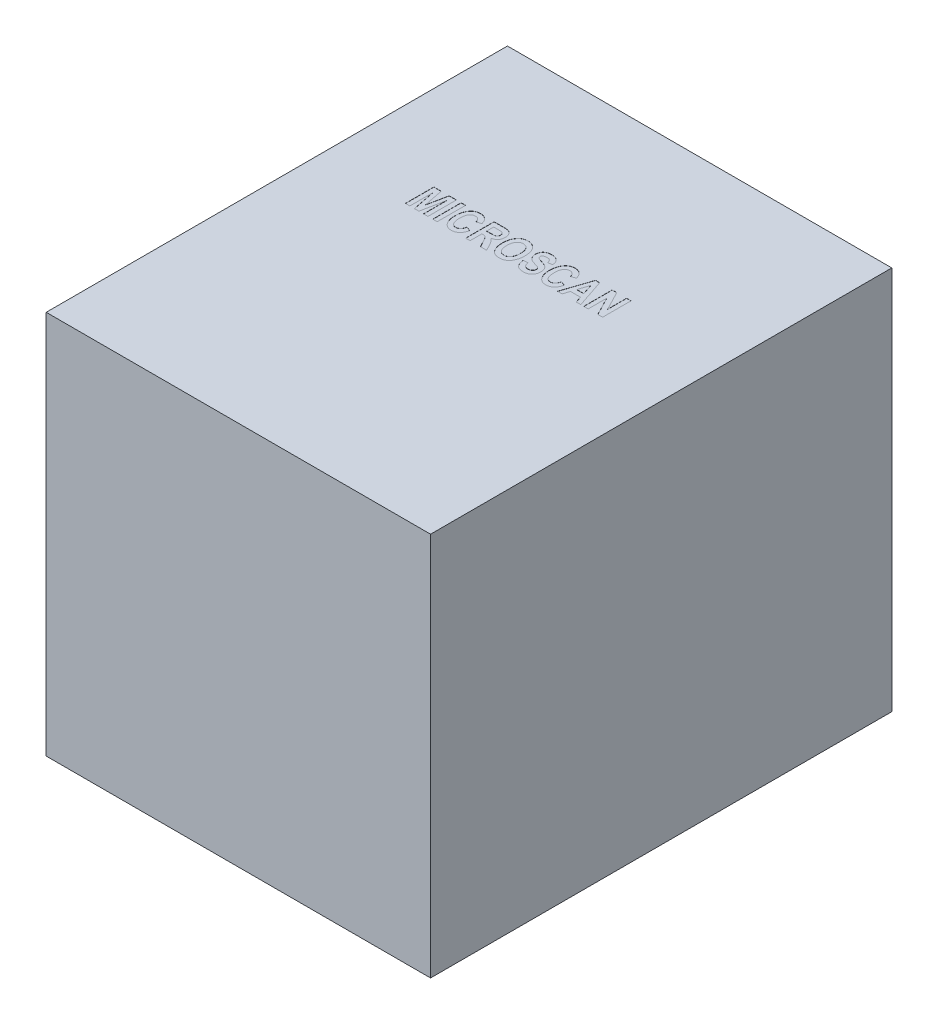
from build123d import *

# Parameters (mm, degrees)
SKETCH1_W           = 250
SKETCH1_H           = 250
BOSS_EXTRUDE1_DEPTH = 300
SKETCH2_W           = 2.881853693
SKETCH2_H           = 18.491894532
CUT_EXTRUDE1_DEPTH  = 0.1


with BuildPart() as part:
    # Sketch1 → Boss-Extrude1 (new body)
    with BuildSketch(Plane.XY):
        Rectangle(SKETCH1_W, SKETCH1_H)
    extrude(amount=BOSS_EXTRUDE1_DEPTH)

    # Sketch2 → Cut-Extrude1 (cut)
    with BuildSketch(Plane(origin=(0, 125, 0), x_dir=(1, 0, 0), z_dir=(0, 1, 0))):
        Polygon((-69.512052885, -121.832281684), (-69.512052885, -103.340387152), (-64.74273512, -103.340387152), (-62.187341415, -116.196156362), (-59.583166333, -103.340387152), (-54.862629945, -103.340387152), (-54.862629945, -121.832281684), (-57.744483638, -121.832281684), (-57.744483638, -107.03651461), (-60.750166982, -121.832281684), (-63.680802053, -121.832281684), (-66.630199192, -107.03651461), (-66.630199192, -121.832281684), align=None)
        with Locations((-50.299694931, -112.586334418)):
            Rectangle(SKETCH2_W, SKETCH2_H)
        with BuildLine():
            Line((-36.130580939, -115.107956399), (-33.248727246, -116.308728772))
            add(Edge.make_bspline(
                [(-33.248727246, -116.308728772), (-33.308245743, -116.550975126), (-33.424220471, -117.023004107), (-33.643628678, -117.697666192), (-33.885062341, -118.323649851), (-34.161276007, -118.897451219), (-34.462799732, -119.424104457), (-34.797731244, -119.898427101), (-35.159769117, -120.32284771), (-35.55097253, -120.696374595), (-35.970707039, -121.017764628), (-36.407187584, -121.304155773), (-36.87168537, -121.538935512), (-37.357696184, -121.737170875), (-37.869040952, -121.884525922), (-38.401834597, -121.995416695), (-38.958363997, -122.058873566), (-39.33748846, -122.067864433), (-39.530267718, -122.072436158)],
                knots=[0, 0, 0, 0, 0.000748124, 0.001457757, 0.002126709, 0.002759444, 0.003366373, 0.003945231, 0.004498759, 0.005037554, 0.005564458, 0.006082794, 0.00660136, 0.00712327, 0.007655213, 0.008195378, 0.008754387, 0.009332697, 0.009332697, 0.009332697, 0.009332697], degree=3))
            add(Edge.make_bspline(
                [(-39.530267718, -122.072436158), (-39.772147001, -122.066998117), (-40.245982801, -122.056345123), (-40.937400287, -121.941721554), (-41.595343591, -121.767571007), (-42.218626723, -121.517489733), (-42.807988765, -121.197832615), (-43.357203628, -120.801890323), (-43.879086754, -120.344403118), (-44.182525847, -119.987697921), (-44.33710962, -119.805978306)],
                knots=[0, 0, 0, 0, 0.000725003, 0.001420263, 0.002096583, 0.002763426, 0.003430058, 0.004102693, 0.004791065, 0.005505926, 0.005505926, 0.005505926, 0.005505926], degree=3))
            add(Edge.make_bspline(
                [(-44.33710962, -119.805978306), (-44.507028249, -119.581622631), (-44.849345032, -119.129637387), (-45.27910475, -118.384314521), (-45.644623638, -117.583590363), (-45.94378282, -116.726739165), (-46.176961635, -115.812811637), (-46.339983902, -114.841372068), (-46.437883745, -113.812890342), (-46.450679072, -113.108138763), (-46.45722334, -112.747688205)],
                knots=[0, 0, 0, 0, 0.000843651, 0.001699612, 0.00257444, 0.003481128, 0.00441854, 0.005400641, 0.006433421, 0.007514643, 0.007514643, 0.007514643, 0.007514643], degree=3))
            add(Edge.make_bspline(
                [(-46.45722334, -112.747688205), (-46.451244677, -112.367181685), (-46.439599246, -111.626018829), (-46.334749776, -110.546956168), (-46.174911255, -109.529656896), (-45.936598651, -108.57790215), (-45.638059623, -107.68622688), (-45.269215514, -106.860191453), (-44.840950487, -106.091156805), (-44.491535179, -105.631863367), (-44.318347552, -105.404214667)],
                knots=[0, 0, 0, 0, 0.001141234, 0.002222931, 0.003249448, 0.0042278, 0.005162866, 0.006066598, 0.006938814, 0.007795984, 0.007795984, 0.007795984, 0.007795984], degree=3))
            add(Edge.make_bspline(
                [(-44.318347552, -105.404214667), (-44.161101744, -105.220196591), (-43.851203985, -104.857536436), (-43.321514999, -104.387917013), (-42.75246272, -103.988723778), (-42.144253064, -103.661885925), (-41.494164515, -103.407682111), (-40.805378766, -103.228311936), (-40.075138045, -103.122476347), (-39.575647713, -103.107760563), (-39.320132553, -103.100232678)],
                knots=[0, 0, 0, 0, 0.000725459, 0.001429724, 0.002116785, 0.00280679, 0.003495949, 0.004205869, 0.004937667, 0.005704078, 0.005704078, 0.005704078, 0.005704078], degree=3))
            add(Edge.make_bspline(
                [(-39.320132553, -103.100232678), (-39.111027938, -103.105237872), (-38.700042629, -103.115075347), (-38.097407195, -103.193720573), (-37.523248784, -103.332007207), (-36.97196277, -103.513396119), (-36.44838585, -103.756092612), (-35.951004084, -104.050590643), (-35.477861501, -104.395921998), (-35.191082298, -104.664384902), (-35.046133391, -104.800076067)],
                knots=[0, 0, 0, 0, 0.000627203, 0.001232739, 0.001818884, 0.002396768, 0.002970986, 0.003546318, 0.004128716, 0.00472392, 0.00472392, 0.00472392, 0.00472392], degree=3))
            add(Edge.make_bspline(
                [(-35.046133391, -104.800076067), (-34.945351822, -104.904655694), (-34.739987328, -105.117759562), (-34.463463574, -105.476719718), (-34.207450557, -105.872044764), (-33.976538318, -106.305421764), (-33.761866544, -106.772614942), (-33.566661836, -107.276019097), (-33.394936079, -107.816779469), (-33.298216436, -108.191761527), (-33.248727246, -108.383631115)],
                knots=[0, 0, 0, 0, 0.000435442, 0.000887308, 0.00135672, 0.001846966, 0.002359071, 0.002898428, 0.003465675, 0.004060051, 0.004060051, 0.004060051, 0.004060051], degree=3))
            Line((-33.248727246, -108.383631115), (-36.130580939, -109.344249013))
            add(Edge.make_bspline(
                [(-36.130580939, -109.344249013), (-36.157661563, -109.221255235), (-36.210355959, -108.981929771), (-36.316152908, -108.63655056), (-36.444956461, -108.315761909), (-36.585096417, -108.011862834), (-36.753848249, -107.73536473), (-36.93036798, -107.47305635), (-37.137353894, -107.240661297), (-37.356028781, -107.025968121), (-37.594105924, -106.840437629), (-37.837799279, -106.672654244), (-38.094374282, -106.533154659), (-38.362760688, -106.420961924), (-38.639779692, -106.330164088), (-38.927495512, -106.26631282), (-39.225249698, -106.227646659), (-39.427583715, -106.224060707), (-39.530267718, -106.222240845)],
                knots=[0, 0, 0, 0, 0.000377728, 0.000734997, 0.001082009, 0.001414347, 0.001737403, 0.002052807, 0.002361327, 0.002669162, 0.002970969, 0.003265504, 0.003555995, 0.003845223, 0.004137141, 0.004429372, 0.004728178, 0.005036082, 0.005036082, 0.005036082, 0.005036082], degree=3))
            add(Edge.make_bspline(
                [(-39.530267718, -106.222240845), (-39.675591067, -106.226549519), (-39.961602282, -106.23502943), (-40.38063334, -106.302497335), (-40.777093646, -106.421829236), (-41.156952055, -106.578488507), (-41.513825515, -106.787205322), (-41.851686875, -107.039964321), (-42.161451398, -107.34440406), (-42.458328016, -107.686846522), (-42.727348467, -108.083609145), (-42.955765195, -108.542161233), (-43.144167535, -109.060865755), (-43.306453933, -109.636002594), (-43.427874002, -110.271350471), (-43.512135797, -110.965925492), (-43.564724652, -111.718720414), (-43.571739715, -112.241022053), (-43.575369647, -112.511286145)],
                knots=[0, 0, 0, 0, 0.000435862, 0.000857821, 0.001268637, 0.001675631, 0.002087543, 0.002505563, 0.002938133, 0.003387875, 0.0038635, 0.004371976, 0.004920522, 0.005516885, 0.006163019, 0.006858837, 0.007614899, 0.008425638, 0.008425638, 0.008425638, 0.008425638], degree=3))
            add(Edge.make_bspline(
                [(-43.575369647, -112.511286145), (-43.571268008, -112.791518101), (-43.563369493, -113.331159978), (-43.517327512, -114.110583737), (-43.429812626, -114.82669565), (-43.317786926, -115.482311511), (-43.16449025, -116.073599201), (-42.977208758, -116.600920856), (-42.761490268, -117.069424538), (-42.504161246, -117.472963397), (-42.219035589, -117.821337574), (-41.915894882, -118.123802259), (-41.58888664, -118.376469421), (-41.246759196, -118.59060339), (-40.88011977, -118.752868428), (-40.493305862, -118.863269922), (-40.088611525, -118.939629283), (-39.810814167, -118.946780225), (-39.669107024, -118.95042799)],
                knots=[0, 0, 0, 0, 0.00084075, 0.00161903, 0.002340919, 0.00300412, 0.003613006, 0.004170843, 0.004681129, 0.005156858, 0.005602259, 0.006029457, 0.006438539, 0.006839486, 0.007237631, 0.007636589, 0.008044378, 0.008468998, 0.008468998, 0.008468998, 0.008468998], degree=3))
            add(Edge.make_bspline(
                [(-39.669107024, -118.95042799), (-39.565176792, -118.94720921), (-39.359008339, -118.940824051), (-39.055629668, -118.900165212), (-38.76287434, -118.827467968), (-38.480702869, -118.726608782), (-38.210317863, -118.593537978), (-37.948945173, -118.435887714), (-37.701864847, -118.246390382), (-37.462665743, -118.031225479), (-37.237057828, -117.78374781), (-37.030869437, -117.499218197), (-36.83929712, -117.182721914), (-36.663499019, -116.832296092), (-36.50235394, -116.450192983), (-36.360271354, -116.033480409), (-36.231699808, -115.584238807), (-36.164936459, -115.269775158), (-36.130580939, -115.107956399)],
                knots=[0, 0, 0, 0, 0.000311812, 0.000618547, 0.000916149, 0.001215262, 0.001515666, 0.001818776, 0.00212948, 0.00244828, 0.002782982, 0.003131977, 0.003500727, 0.003891735, 0.004307102, 0.004743803, 0.005211817, 0.00570796, 0.00570796, 0.00570796, 0.00570796], degree=3))
        make_face()
        with BuildLine():
            Line((-30.366873553, -121.832281684), (-30.366873553, -103.340387152))
            Line((-30.366873553, -103.340387152), (-23.875197916, -103.340387152))
            add(Edge.make_bspline(
                [(-23.875197916, -103.340387152), (-23.675057607, -103.341851226), (-23.289649913, -103.344670576), (-22.732520302, -103.365438256), (-22.220977299, -103.408440344), (-21.752128088, -103.457954239), (-21.329978896, -103.528766813), (-20.951451163, -103.614889943), (-20.617052779, -103.714304306), (-20.229207416, -103.86890571), (-19.794637529, -104.124732531), (-19.327311543, -104.517039685), (-18.911566219, -105.003019248), (-18.546628352, -105.571404362), (-18.245371653, -106.216351583), (-18.034126145, -106.930836609), (-17.89840513, -107.704290931), (-17.885495704, -108.241688867), (-17.878840883, -108.518718007)],
                knots=[0, 0, 0, 0, 0.000600433, 0.001156246, 0.001671982, 0.002140237, 0.002570212, 0.002955251, 0.003304245, 0.003615718, 0.004205898, 0.0048079, 0.005438361, 0.006116999, 0.006828811, 0.007565976, 0.008346352, 0.009176662, 0.009176662, 0.009176662, 0.009176662], degree=3))
            add(Edge.make_bspline(
                [(-17.878840883, -108.518718007), (-17.882959025, -108.695182705), (-17.891006767, -109.040032963), (-17.938747147, -109.544607506), (-18.023948209, -110.023305924), (-18.149947807, -110.473956259), (-18.301506928, -110.901667028), (-18.494729482, -111.300438966), (-18.720313605, -111.674008778), (-18.979599565, -112.019408637), (-19.269727389, -112.336396038), (-19.590583568, -112.622481079), (-19.940019556, -112.879718136), (-20.322616294, -113.098859691), (-20.728147591, -113.297417019), (-21.166619996, -113.456658766), (-21.632976673, -113.589822519), (-21.957125605, -113.6508459), (-22.122820735, -113.682039207)],
                knots=[0, 0, 0, 0, 0.000529423, 0.001034607, 0.001518916, 0.001985922, 0.002436992, 0.002878392, 0.003312781, 0.003744309, 0.004171903, 0.00459976, 0.00503207, 0.00547099, 0.005920779, 0.006385003, 0.006868482, 0.007374057, 0.007374057, 0.007374057, 0.007374057], degree=3))
            add(Edge.make_bspline(
                [(-22.122820735, -113.682039207), (-21.958557305, -113.798658374), (-21.637154645, -114.026838865), (-21.192287022, -114.399875697), (-20.794329961, -114.790850175), (-20.489478771, -115.136808758), (-20.259493026, -115.445724373), (-20.068011841, -115.715098496), (-19.862476092, -116.027299628), (-19.64022376, -116.380876203), (-19.405387195, -116.778431968), (-19.153964082, -117.217510831), (-18.887157059, -117.69959873), (-18.705323069, -118.035927234), (-18.610561547, -118.211202499)],
                knots=[0, 0, 0, 0, 0.000604185, 0.001182167, 0.001739397, 0.002276661, 0.002563346, 0.002894431, 0.003268056, 0.003684506, 0.004147211, 0.004653133, 0.005202384, 0.005800138, 0.005800138, 0.005800138, 0.005800138], degree=3))
            Line((-18.610561547, -118.211202499), (-16.67806851, -121.832281684))
            Line((-16.67806851, -121.832281684), (-20.726922853, -121.832281684))
            Line((-20.726922853, -121.832281684), (-22.869551054, -117.832208719))
            add(Edge.make_bspline(
                [(-22.869551054, -117.832208719), (-22.961757882, -117.659407949), (-23.137240325, -117.330544003), (-23.393057355, -116.864316303), (-23.625547224, -116.449665206), (-23.830993428, -116.082402527), (-24.01893787, -115.770074703), (-24.179365324, -115.503924241), (-24.320998334, -115.292077528), (-24.47383548, -115.078048208), (-24.652307712, -114.862758389), (-24.875513545, -114.650253733), (-25.103812096, -114.479105798), (-25.35008119, -114.347900463), (-25.635196001, -114.249266443), (-25.982303031, -114.193631292), (-26.398200074, -114.149667633), (-26.699348992, -114.148155698), (-26.862119192, -114.147338502)],
                knots=[0, 0, 0, 0, 0.000587585, 0.001118257, 0.001595345, 0.002013768, 0.002380585, 0.002688854, 0.002945915, 0.003144828, 0.00347778, 0.00378302, 0.004067462, 0.004331014, 0.00461701, 0.004968077, 0.005382901, 0.005870845, 0.005870845, 0.005870845, 0.005870845], degree=3))
            Line((-26.862119192, -114.147338502), (-27.48501986, -114.147338502))
            Line((-27.48501986, -114.147338502), (-27.48501986, -121.832281684))
            Line((-27.48501986, -121.832281684), (-30.366873553, -121.832281684))
        make_face()
        with BuildLine():
            Line((-27.48501986, -111.025330334), (-25.019684083, -111.025330334))
            add(Edge.make_bspline(
                [(-25.019684083, -111.025330334), (-24.839568727, -111.024275742), (-24.496833907, -111.022268997), (-24.008915709, -111.016378036), (-23.572392377, -111.000457627), (-23.188312661, -110.982422833), (-22.854109318, -110.960710581), (-22.572097882, -110.93291823), (-22.34056348, -110.895006065), (-22.101383067, -110.842836305), (-21.847796136, -110.746467225), (-21.581146695, -110.584494087), (-21.339623238, -110.383766999), (-21.133150012, -110.133124813), (-20.961330408, -109.838074651), (-20.843440677, -109.495328753), (-20.770691689, -109.1096757), (-20.764141548, -108.83803221), (-20.760694576, -108.695081449)],
                knots=[0, 0, 0, 0, 0.000540361, 0.001028232, 0.001463771, 0.001850725, 0.002181704, 0.002468463, 0.002700415, 0.0028852, 0.003202296, 0.003508618, 0.003817549, 0.004139929, 0.004477834, 0.004836263, 0.005221904, 0.005650272, 0.005650272, 0.005650272, 0.005650272], degree=3))
            add(Edge.make_bspline(
                [(-20.760694576, -108.695081449), (-20.764325534, -108.558408702), (-20.771276786, -108.296756938), (-20.842575898, -107.925523978), (-20.962472367, -107.595895696), (-21.133751675, -107.310750913), (-21.346208995, -107.069865137), (-21.591861576, -106.865485305), (-21.87332002, -106.70250145), (-22.08133041, -106.632773815), (-22.186611768, -106.597482212)],
                knots=[0, 0, 0, 0, 0.000409632, 0.000784216, 0.00112854, 0.001456742, 0.001775852, 0.002087664, 0.002412068, 0.002744533, 0.002744533, 0.002744533, 0.002744533], degree=3))
            add(Edge.make_bspline(
                [(-22.186611768, -106.597482212), (-22.234047873, -106.586997883), (-22.346959079, -106.562042246), (-22.546049369, -106.53277802), (-22.801777801, -106.512793667), (-23.112037668, -106.494096558), (-23.477356902, -106.479894022), (-23.897632335, -106.467561861), (-24.373026544, -106.466567594), (-24.708236971, -106.463833681), (-24.884597191, -106.46239532)],
                knots=[0, 0, 0, 0, 0.000145717, 0.000346848, 0.000603004, 0.000915019, 0.001279312, 0.001699733, 0.002176304, 0.002705408, 0.002705408, 0.002705408, 0.002705408], degree=3))
            Line((-24.884597191, -106.46239532), (-27.48501986, -106.46239532))
            Line((-27.48501986, -106.46239532), (-27.48501986, -111.025330334))
        make_face(mode=Mode.SUBTRACT)
        with BuildLine():
            add(Edge.make_bspline(
                [(-15.717450613, -112.698906828), (-15.714742498, -112.431162632), (-15.709448806, -111.907789105), (-15.663114611, -111.141660822), (-15.590760326, -110.411125062), (-15.479637061, -109.71809955), (-15.348666162, -109.058939898), (-15.176253638, -108.439045196), (-14.985518604, -107.851207447), (-14.752904257, -107.303679258), (-14.502920708, -106.787783586), (-14.228610049, -106.309145489), (-13.938809536, -105.861496941), (-13.627337384, -105.450411245), (-13.30061535, -105.069104649), (-12.95593238, -104.722257492), (-12.588391349, -104.413992236), (-12.205436104, -104.133617676), (-11.79917974, -103.88997034), (-11.372957855, -103.679973321), (-10.928665797, -103.497937817), (-10.461619327, -103.351618568), (-9.973086841, -103.240755069), (-9.464530766, -103.157240773), (-8.935327422, -103.107830083), (-8.575460441, -103.10279117), (-8.392739143, -103.100232678)],
                knots=[0, 0, 0, 0, 0.000803157, 0.001569972, 0.002301799, 0.003004473, 0.003674896, 0.004316657, 0.004933698, 0.005527446, 0.006099711, 0.006652641, 0.007181359, 0.007698444, 0.008198656, 0.008686874, 0.009163489, 0.009636353, 0.010109351, 0.010582586, 0.011060603, 0.011548374, 0.012049008, 0.012562266, 0.013093601, 0.013641659, 0.013641659, 0.013641659, 0.013641659], degree=3))
            add(Edge.make_bspline(
                [(-8.392739143, -103.100232678), (-8.128350767, -103.106763931), (-7.609412175, -103.119583402), (-6.851037102, -103.240529661), (-6.12890729, -103.430040989), (-5.444691849, -103.702231494), (-4.799652549, -104.054162606), (-4.192109905, -104.481364238), (-3.621842424, -104.984424641), (-3.094113344, -105.563326551), (-2.612383652, -106.210347599), (-2.1994831, -106.931400876), (-1.845024666, -107.713396717), (-1.562597273, -108.564652656), (-1.33587271, -109.477565867), (-1.183810433, -110.457171914), (-1.0816012, -111.499714387), (-1.072640183, -112.217082878), (-1.068027672, -112.586334418)],
                knots=[0, 0, 0, 0, 0.000792648, 0.001555801, 0.002297622, 0.003028572, 0.003758993, 0.004497084, 0.00525215, 0.00603565, 0.006843186, 0.00766701, 0.008523514, 0.009414671, 0.010353892, 0.011342167, 0.012386154, 0.013493523, 0.013493523, 0.013493523, 0.013493523], degree=3))
            add(Edge.make_bspline(
                [(-1.068027672, -112.586334418), (-1.074173471, -112.959314722), (-1.086159026, -113.686702032), (-1.188968258, -114.746347802), (-1.355552548, -115.743986878), (-1.591072012, -116.678375325), (-1.895197823, -117.550577942), (-2.267454436, -118.360030173), (-2.70385526, -119.111140753), (-3.055305788, -119.560731841), (-3.229417942, -119.783463824)],
                knots=[0, 0, 0, 0, 0.001118729, 0.002181749, 0.003190374, 0.00415053, 0.005069082, 0.005957271, 0.006820269, 0.007667567, 0.007667567, 0.007667567, 0.007667567], degree=3))
            add(Edge.make_bspline(
                [(-3.229417942, -119.783463824), (-3.390459268, -119.966317288), (-3.708127215, -120.327011566), (-4.251309948, -120.794348831), (-4.834486499, -121.191887695), (-5.464005744, -121.511174817), (-6.132669153, -121.765244491), (-6.845180163, -121.944695204), (-7.60032922, -122.050095984), (-8.117225278, -122.064878687), (-8.381481902, -122.072436158)],
                knots=[0, 0, 0, 0, 0.000730257, 0.001440495, 0.002143008, 0.002842821, 0.003552989, 0.00428471, 0.005042512, 0.00583516, 0.00583516, 0.00583516, 0.00583516], degree=3))
            add(Edge.make_bspline(
                [(-8.381481902, -122.072436158), (-8.648336915, -122.067052107), (-9.16939353, -122.056539301), (-9.928154051, -121.942321884), (-10.644926872, -121.769250469), (-11.317594962, -121.52022173), (-11.946328095, -121.199045514), (-12.529342601, -120.804530684), (-13.078335754, -120.347350137), (-13.395397996, -119.988045696), (-13.556060343, -119.805978306)],
                knots=[0, 0, 0, 0, 0.000799977, 0.001562022, 0.00229647, 0.003008836, 0.003708649, 0.004409065, 0.005117268, 0.005844771, 0.005844771, 0.005844771, 0.005844771], degree=3))
            add(Edge.make_bspline(
                [(-13.556060343, -119.805978306), (-13.729896006, -119.583075734), (-14.079464582, -119.134837823), (-14.518249717, -118.390436125), (-14.890317155, -117.58821685), (-15.193153674, -116.725686777), (-15.430199964, -115.804228977), (-15.596194758, -114.822675445), (-15.699408836, -113.780563742), (-15.711333564, -113.065641651), (-15.717450613, -112.698906828)],
                knots=[0, 0, 0, 0, 0.000847298, 0.001703843, 0.002585221, 0.003496695, 0.004442311, 0.005436141, 0.006480485, 0.007580461, 0.007580461, 0.007580461, 0.007580461], degree=3))
        make_face()
        with BuildLine():
            add(Edge.make_bspline(
                [(-12.83559692, -112.575077177), (-12.832549165, -112.832870155), (-12.826651779, -113.331698049), (-12.765711193, -114.054919657), (-12.666409792, -114.728577048), (-12.523802862, -115.353188805), (-12.34499019, -115.928586879), (-12.12856781, -116.456262319), (-11.864277025, -116.930703314), (-11.563421462, -117.356093503), (-11.233690113, -117.73082511), (-10.882610113, -118.056234001), (-10.512589351, -118.33360834), (-10.122112377, -118.559161591), (-9.711362823, -118.73458568), (-9.282671204, -118.857005524), (-8.834617958, -118.935458429), (-8.529407304, -118.945376936), (-8.373977074, -118.95042799)],
                knots=[0, 0, 0, 0, 0.000773225, 0.001496186, 0.002175466, 0.002814479, 0.003416189, 0.00398136, 0.004522228, 0.005041758, 0.005541604, 0.006016918, 0.006475466, 0.006926005, 0.007366495, 0.007811832, 0.008260932, 0.008726972, 0.008726972, 0.008726972, 0.008726972], degree=3))
            add(Edge.make_bspline(
                [(-8.373977074, -118.95042799), (-8.217374639, -118.944916937), (-7.91003453, -118.93410122), (-7.458558083, -118.862462015), (-7.029052138, -118.738105021), (-6.620255884, -118.563129848), (-6.230273079, -118.341778205), (-5.866799647, -118.063150922), (-5.517726375, -117.743518886), (-5.195224259, -117.369069475), (-4.898058831, -116.946595104), (-4.640981635, -116.468135394), (-4.429315563, -115.935800382), (-4.253815758, -115.351793715), (-4.11491727, -114.715883259), (-4.020712669, -114.02703377), (-3.958573337, -113.286676513), (-3.952841382, -112.775342247), (-3.949881366, -112.511286145)],
                knots=[0, 0, 0, 0, 0.000469787, 0.00092198, 0.001367317, 0.001807806, 0.002253223, 0.002708766, 0.003178778, 0.003670859, 0.00418823, 0.004725494, 0.005296181, 0.005903957, 0.006553135, 0.007246723, 0.007988382, 0.008780364, 0.008780364, 0.008780364, 0.008780364], degree=3))
            add(Edge.make_bspline(
                [(-3.949881366, -112.511286145), (-3.953421357, -112.252286666), (-3.960287953, -111.74989988), (-4.014678084, -111.022620803), (-4.113898236, -110.348951873), (-4.240943911, -109.726433796), (-4.415506224, -109.15718652), (-4.621686167, -108.636596768), (-4.875689261, -108.172704395), (-5.161707486, -107.759150075), (-5.481934392, -107.39927647), (-5.82555466, -107.085117908), (-6.190674438, -106.816735563), (-6.579805266, -106.595272496), (-6.996651957, -106.431479598), (-7.43438183, -106.311745228), (-7.895803297, -106.232298833), (-8.212285774, -106.225641887), (-8.373977074, -106.222240845)],
                knots=[0, 0, 0, 0, 0.000776976, 0.001507117, 0.002185848, 0.002818772, 0.003411095, 0.00396994, 0.004495519, 0.004994139, 0.005475283, 0.005937454, 0.006388525, 0.006832088, 0.00727665, 0.007728189, 0.008192094, 0.008676679, 0.008676679, 0.008676679, 0.008676679], degree=3))
            add(Edge.make_bspline(
                [(-8.373977074, -106.222240845), (-8.535691421, -106.225574173), (-8.852219008, -106.232098579), (-9.314507787, -106.312705904), (-9.755007713, -106.429542894), (-10.171780288, -106.600922297), (-10.564760051, -106.82009906), (-10.934635443, -107.088856686), (-11.281213556, -107.406733642), (-11.604215139, -107.771710094), (-11.901001474, -108.185915691), (-12.150025307, -108.6597614), (-12.364109555, -109.182312584), (-12.536453142, -109.759480569), (-12.669026736, -110.38851346), (-12.765214527, -111.070478966), (-12.826901063, -111.804697475), (-12.832630496, -112.31227703), (-12.83559692, -112.575077177)],
                knots=[0, 0, 0, 0, 0.000484585, 0.00094849, 0.001403647, 0.001849616, 0.002296453, 0.002750557, 0.00321803, 0.003704471, 0.004210477, 0.004742658, 0.005306395, 0.005902309, 0.006547025, 0.007233184, 0.007967363, 0.008755594, 0.008755594, 0.008755594, 0.008755594], degree=3))
        make_face(mode=Mode.SUBTRACT)
        with BuildLine():
            Line((0.853208123, -115.588265348), (3.735061816, -115.348110874))
            add(Edge.make_bspline(
                [(3.735061816, -115.348110874), (3.758307582, -115.493547749), (3.803637674, -115.777154959), (3.89916029, -116.184880197), (4.005303451, -116.567544149), (4.138185175, -116.918575841), (4.282957528, -117.245674311), (4.452691258, -117.540528748), (4.636783175, -117.811560032), (4.843255681, -118.050628122), (5.066766819, -118.26331512), (5.307177172, -118.448901223), (5.569031135, -118.60269464), (5.847367832, -118.732007695), (6.146497556, -118.828258412), (6.462667713, -118.900553606), (6.798478864, -118.941229706), (7.028325748, -118.947313254), (7.146005836, -118.95042799)],
                knots=[0, 0, 0, 0, 0.000441702, 0.000861336, 0.001255643, 0.001632027, 0.001986367, 0.002327527, 0.002651236, 0.002967888, 0.003273128, 0.003575587, 0.003876764, 0.004182349, 0.004494432, 0.004817597, 0.005154103, 0.005507149, 0.005507149, 0.005507149, 0.005507149], degree=3))
            add(Edge.make_bspline(
                [(7.146005836, -118.95042799), (7.262419718, -118.948386773), (7.489505702, -118.944405016), (7.819401603, -118.91008914), (8.131241394, -118.854955172), (8.421920754, -118.771874077), (8.695720687, -118.669646017), (8.952222406, -118.548264843), (9.184452172, -118.395026701), (9.400022394, -118.227634131), (9.589465815, -118.038713664), (9.760695491, -117.842018904), (9.899314722, -117.628104014), (10.017361352, -117.406793292), (10.107340476, -117.17346954), (10.17078048, -116.929195621), (10.214847098, -116.675556349), (10.217762528, -116.501542406), (10.219232626, -116.413796354)],
                knots=[0, 0, 0, 0, 0.000349156, 0.000681091, 0.000993895, 0.001298002, 0.001586548, 0.001870172, 0.002147038, 0.002419547, 0.002687549, 0.002948443, 0.003200302, 0.003450394, 0.003699866, 0.003948349, 0.00420683, 0.00446974, 0.00446974, 0.00446974, 0.00446974], degree=3))
            add(Edge.make_bspline(
                [(10.219232626, -116.413796354), (10.215801514, -116.312221818), (10.209136685, -116.114916431), (10.152453717, -115.829630458), (10.054803291, -115.568427494), (9.915978344, -115.33138972), (9.742094165, -115.115706514), (9.527040968, -114.920782603), (9.269954691, -114.750195099), (9.022520463, -114.621721759), (8.786902266, -114.518005346), (8.555744745, -114.434760269), (8.27983658, -114.330931606), (7.95139996, -114.225202715), (7.578069817, -114.100705958), (7.156209688, -113.963800155), (6.682969574, -113.824157752), (6.351671421, -113.723554948), (6.177883111, -113.670781967)],
                knots=[0, 0, 0, 0, 0.000304524, 0.000591528, 0.000868217, 0.001137241, 0.001412091, 0.00169631, 0.002004374, 0.002335034, 0.002531633, 0.002776261, 0.003071845, 0.003415964, 0.003811109, 0.004252557, 0.004746395, 0.005291271, 0.005291271, 0.005291271, 0.005291271], degree=3))
            add(Edge.make_bspline(
                [(6.177883111, -113.670781967), (6.019905782, -113.623148923), (5.71383116, -113.530861845), (5.274848592, -113.377836879), (4.865207925, -113.232713046), (4.493568501, -113.07111163), (4.14937526, -112.91613744), (3.840715934, -112.751730808), (3.563446356, -112.585771145), (3.237589293, -112.361429782), (2.874581482, -112.046307626), (2.48887813, -111.618268917), (2.149888949, -111.137837986), (1.858332608, -110.609876788), (1.621874944, -110.044406846), (1.458313204, -109.448941326), (1.352194642, -108.835213059), (1.339780403, -108.417842705), (1.333517072, -108.207267673)],
                knots=[0, 0, 0, 0, 0.000494935, 0.000958916, 0.0013946, 0.001798137, 0.002174222, 0.002526729, 0.002846566, 0.00314322, 0.003712624, 0.004283841, 0.00486793, 0.005472581, 0.006089998, 0.006701826, 0.007321804, 0.007953113, 0.007953113, 0.007953113, 0.007953113], degree=3))
            add(Edge.make_bspline(
                [(1.333517072, -108.207267673), (1.342021805, -107.963976311), (1.358721853, -107.486244957), (1.495079789, -106.788649411), (1.711478042, -106.127660242), (2.017332557, -105.51075815), (2.397343914, -104.947813229), (2.852102199, -104.454992233), (3.373571895, -104.037148365), (3.96195254, -103.692146902), (4.622226236, -103.425756894), (5.352483126, -103.236970707), (6.15276639, -103.118498449), (6.710287179, -103.106473885), (6.999661703, -103.100232678)],
                knots=[0, 0, 0, 0, 0.00072936, 0.001432184, 0.002123983, 0.002810346, 0.003491014, 0.004154884, 0.004814167, 0.005488621, 0.006193805, 0.006942879, 0.007746851, 0.00861447, 0.00861447, 0.00861447, 0.00861447], degree=3))
            add(Edge.make_bspline(
                [(6.999661703, -103.100232678), (7.219972099, -103.104400215), (7.650415725, -103.11254277), (8.276771564, -103.180309474), (8.865042776, -103.293300928), (9.417758635, -103.445668221), (9.932691013, -103.647449705), (10.408294305, -103.898968192), (10.85218389, -104.185426744), (11.248503638, -104.527813712), (11.612442887, -104.902340454), (11.928717757, -105.320756398), (12.195261433, -105.779769892), (12.4217532, -106.273121313), (12.602214963, -106.806361159), (12.735493873, -107.378231839), (12.82702084, -107.988227215), (12.849435932, -108.408329762), (12.860931845, -108.62378559)],
                knots=[0, 0, 0, 0, 0.000660808, 0.001291091, 0.001887194, 0.002456238, 0.003008812, 0.003542553, 0.004068132, 0.00458992, 0.005110086, 0.005632427, 0.006158862, 0.006699536, 0.007258444, 0.00784459, 0.008459115, 0.009106099, 0.009106099, 0.009106099, 0.009106099], degree=3))
            Line((12.860931845, -108.62378559), (9.979078151, -108.863940064))
            add(Edge.make_bspline(
                [(9.979078151, -108.863940064), (9.958800182, -108.746189824), (9.919572181, -108.51840042), (9.846465993, -108.190144319), (9.752407113, -107.890704916), (9.644600089, -107.617037336), (9.516463751, -107.37458736), (9.377757811, -107.155937037), (9.218919187, -106.967905034), (8.986791844, -106.749546519), (8.638627987, -106.53200965), (8.15438462, -106.349063562), (7.594664638, -106.241704786), (7.197777305, -106.228962746), (6.988404462, -106.222240845)],
                knots=[0, 0, 0, 0, 0.000358449, 0.000693424, 0.001007934, 0.001299199, 0.001574459, 0.001829457, 0.002074487, 0.00231077, 0.002783336, 0.003294133, 0.003856369, 0.004484145, 0.004484145, 0.004484145, 0.004484145], degree=3))
            add(Edge.make_bspline(
                [(6.988404462, -106.222240845), (6.779105913, -106.226955226), (6.383143261, -106.235874154), (5.826055416, -106.329417989), (5.341625217, -106.482657571), (4.939932113, -106.705861134), (4.619724883, -106.971706402), (4.384681188, -107.274876223), (4.240245676, -107.616230855), (4.223710334, -107.856959428), (4.215370765, -107.97837044)],
                knots=[0, 0, 0, 0, 0.000627372, 0.001186897, 0.001688837, 0.002144056, 0.002556771, 0.002929017, 0.003285792, 0.003648827, 0.003648827, 0.003648827, 0.003648827], degree=3))
            add(Edge.make_bspline(
                [(4.215370765, -107.97837044), (4.223458036, -108.096986832), (4.239357014, -108.330177896), (4.36276773, -108.664362338), (4.566025429, -108.968308967), (4.75269181, -109.131834734), (4.849528674, -109.216666949)],
                knots=[0, 0, 0, 0, 0.000355134, 0.000698167, 0.001055139, 0.001439959, 0.001439959, 0.001439959, 0.001439959], degree=3))
            add(Edge.make_bspline(
                [(4.849528674, -109.216666949), (4.908667122, -109.260597132), (5.039385788, -109.357699698), (5.274874358, -109.482945478), (5.55133559, -109.624918635), (5.881079923, -109.75990116), (6.253651966, -109.907759932), (6.678178863, -110.052337384), (7.148097511, -110.206316216), (7.479728194, -110.305634003), (7.65258168, -110.357400702)],
                knots=[0, 0, 0, 0, 0.000220724, 0.000487884, 0.000798338, 0.001153095, 0.001555864, 0.002000885, 0.00249809, 0.003039375, 0.003039375, 0.003039375, 0.003039375], degree=3))
            add(Edge.make_bspline(
                [(7.65258168, -110.357400702), (7.838142196, -110.413582448), (8.197115494, -110.522267997), (8.710622484, -110.701988889), (9.188203341, -110.871284268), (9.624085287, -111.047365687), (10.018781636, -111.22832855), (10.375913586, -111.407891454), (10.695037188, -111.586524931), (11.065020634, -111.824820543), (11.471109236, -112.156286593), (11.905449465, -112.598212084), (12.265022227, -113.106097674), (12.574165261, -113.659678638), (12.809233208, -114.275697698), (12.982407721, -114.947342079), (13.083317142, -115.681530766), (13.095016471, -116.190835367), (13.101086319, -116.455072904)],
                knots=[0, 0, 0, 0, 0.000581564, 0.001125055, 0.001631909, 0.002101561, 0.002534782, 0.00293418, 0.003300478, 0.003631457, 0.004253238, 0.004868908, 0.005484407, 0.006114209, 0.006766449, 0.007456322, 0.008191307, 0.008983786, 0.008983786, 0.008983786, 0.008983786], degree=3))
            add(Edge.make_bspline(
                [(13.101086319, -116.455072904), (13.097385597, -116.649213234), (13.090101284, -117.031349181), (13.013955568, -117.59179245), (12.905387419, -118.130585963), (12.741437935, -118.645579197), (12.531979832, -119.135175333), (12.277697784, -119.603109244), (11.976964222, -120.045147711), (11.632688758, -120.463398231), (11.23820879, -120.845505618), (10.7885906, -121.176295228), (10.287557473, -121.457512115), (9.732607305, -121.679788989), (9.128102885, -121.856439672), (8.472509529, -121.983042948), (7.764378383, -122.057571777), (7.275022962, -122.067372294), (7.022176185, -122.072436158)],
                knots=[0, 0, 0, 0, 0.00058206, 0.001145697, 0.001693973, 0.002229202, 0.002763799, 0.003289378, 0.003824331, 0.004365316, 0.004912011, 0.005467381, 0.006035224, 0.006631008, 0.007256761, 0.007922029, 0.008631464, 0.009389906, 0.009389906, 0.009389906, 0.009389906], degree=3))
            add(Edge.make_bspline(
                [(7.022176185, -122.072436158), (6.796831681, -122.067324655), (6.358598242, -122.05738418), (5.720281271, -121.982293914), (5.121493486, -121.854161823), (4.559033237, -121.680346826), (4.037398177, -121.447494531), (3.550119773, -121.171562342), (3.105340655, -120.838508951), (2.699818344, -120.454805691), (2.332099741, -120.021501708), (1.999065276, -119.538733822), (1.712232697, -119.002076165), (1.458398202, -118.418071579), (1.252383699, -117.780788189), (1.073890398, -117.096215493), (0.940131872, -116.359634656), (0.882711874, -115.850084337), (0.853208123, -115.588265348)],
                knots=[0, 0, 0, 0, 0.000675945, 0.001314528, 0.00192465, 0.002510916, 0.003077083, 0.003635134, 0.004187491, 0.004739619, 0.005306582, 0.005889451, 0.006495591, 0.007129227, 0.007797293, 0.008502637, 0.009250413, 0.010040713, 0.010040713, 0.010040713, 0.010040713], degree=3))
        make_face()
        with BuildLine():
            Line((25.348964515, -115.107956399), (28.230818208, -116.308728772))
            add(Edge.make_bspline(
                [(28.230818208, -116.308728772), (28.171299712, -116.550975126), (28.055324983, -117.023004107), (27.835916777, -117.697666192), (27.594483113, -118.323649851), (27.318269448, -118.897451219), (27.016745722, -119.424104457), (26.68181421, -119.898427101), (26.319776338, -120.32284771), (25.928572925, -120.696374595), (25.508838416, -121.017764628), (25.07235787, -121.304155773), (24.607860084, -121.538935512), (24.12184927, -121.737170875), (23.610504502, -121.884525922), (23.077710857, -121.995416695), (22.521181457, -122.058873566), (22.142056995, -122.067864433), (21.949277736, -122.072436158)],
                knots=[0, 0, 0, 0, 0.000748124, 0.001457757, 0.002126709, 0.002759444, 0.003366373, 0.003945231, 0.004498759, 0.005037554, 0.005564458, 0.006082794, 0.00660136, 0.00712327, 0.007655213, 0.008195378, 0.008754387, 0.009332697, 0.009332697, 0.009332697, 0.009332697], degree=3))
            add(Edge.make_bspline(
                [(21.949277736, -122.072436158), (21.707398454, -122.066998117), (21.233562654, -122.056345123), (20.542145167, -121.941721554), (19.884201864, -121.767571007), (19.260918731, -121.517489733), (18.67155669, -121.197832615), (18.122341827, -120.801890323), (17.6004587, -120.344403118), (17.297019607, -119.987697921), (17.142435834, -119.805978306)],
                knots=[0, 0, 0, 0, 0.000725003, 0.001420263, 0.002096583, 0.002763426, 0.003430058, 0.004102693, 0.004791065, 0.005505926, 0.005505926, 0.005505926, 0.005505926], degree=3))
            add(Edge.make_bspline(
                [(17.142435834, -119.805978306), (16.972517205, -119.581622631), (16.630200422, -119.129637387), (16.200440705, -118.384314521), (15.834921816, -117.583590363), (15.535762634, -116.726739165), (15.30258382, -115.812811637), (15.139561553, -114.841372068), (15.041661709, -113.812890342), (15.028866382, -113.108138763), (15.022322115, -112.747688205)],
                knots=[0, 0, 0, 0, 0.000843651, 0.001699612, 0.00257444, 0.003481128, 0.00441854, 0.005400641, 0.006433421, 0.007514643, 0.007514643, 0.007514643, 0.007514643], degree=3))
            add(Edge.make_bspline(
                [(15.022322115, -112.747688205), (15.028300777, -112.367181685), (15.039946209, -111.626018829), (15.144795679, -110.546956168), (15.304634199, -109.529656896), (15.542946803, -108.57790215), (15.841485832, -107.68622688), (16.210329941, -106.860191453), (16.638594968, -106.091156805), (16.988010276, -105.631863367), (17.161197902, -105.404214667)],
                knots=[0, 0, 0, 0, 0.001141234, 0.002222931, 0.003249448, 0.0042278, 0.005162866, 0.006066598, 0.006938814, 0.007795984, 0.007795984, 0.007795984, 0.007795984], degree=3))
            add(Edge.make_bspline(
                [(17.161197902, -105.404214667), (17.318443711, -105.220196591), (17.628341469, -104.857536436), (18.158030455, -104.387917013), (18.727082734, -103.988723778), (19.335292391, -103.661885925), (19.98538094, -103.407682111), (20.674166688, -103.228311936), (21.404407409, -103.122476347), (21.903897742, -103.107760563), (22.159412902, -103.100232678)],
                knots=[0, 0, 0, 0, 0.000725459, 0.001429724, 0.002116785, 0.00280679, 0.003495949, 0.004205869, 0.004937667, 0.005704078, 0.005704078, 0.005704078, 0.005704078], degree=3))
            add(Edge.make_bspline(
                [(22.159412902, -103.100232678), (22.368517517, -103.105237872), (22.779502826, -103.115075347), (23.382138259, -103.193720573), (23.956296671, -103.332007207), (24.507582685, -103.513396119), (25.031159604, -103.756092612), (25.528541371, -104.050590643), (26.001683953, -104.395921998), (26.288463157, -104.664384902), (26.433412064, -104.800076067)],
                knots=[0, 0, 0, 0, 0.000627203, 0.001232739, 0.001818884, 0.002396768, 0.002970986, 0.003546318, 0.004128716, 0.00472392, 0.00472392, 0.00472392, 0.00472392], degree=3))
            add(Edge.make_bspline(
                [(26.433412064, -104.800076067), (26.534193633, -104.904655694), (26.739558127, -105.117759562), (27.01608188, -105.476719718), (27.272094897, -105.872044764), (27.503007137, -106.305421764), (27.71767891, -106.772614942), (27.912883618, -107.276019097), (28.084609376, -107.816779469), (28.181329019, -108.191761527), (28.230818208, -108.383631115)],
                knots=[0, 0, 0, 0, 0.000435442, 0.000887308, 0.00135672, 0.001846966, 0.002359071, 0.002898428, 0.003465675, 0.004060051, 0.004060051, 0.004060051, 0.004060051], degree=3))
            Line((28.230818208, -108.383631115), (25.348964515, -109.344249013))
            add(Edge.make_bspline(
                [(25.348964515, -109.344249013), (25.321883891, -109.221255235), (25.269189496, -108.981929771), (25.163392547, -108.63655056), (25.034588994, -108.315761909), (24.894449038, -108.011862834), (24.725697206, -107.73536473), (24.549177474, -107.47305635), (24.34219156, -107.240661297), (24.123516674, -107.025968121), (23.885439531, -106.840437629), (23.641746175, -106.672654244), (23.385171173, -106.533154659), (23.116784767, -106.420961924), (22.839765762, -106.330164088), (22.552049943, -106.26631282), (22.254295757, -106.227646659), (22.05196174, -106.224060707), (21.949277736, -106.222240845)],
                knots=[0, 0, 0, 0, 0.000377728, 0.000734997, 0.001082009, 0.001414347, 0.001737403, 0.002052807, 0.002361327, 0.002669162, 0.002970969, 0.003265504, 0.003555995, 0.003845223, 0.004137141, 0.004429372, 0.004728178, 0.005036082, 0.005036082, 0.005036082, 0.005036082], degree=3))
            add(Edge.make_bspline(
                [(21.949277736, -106.222240845), (21.803954388, -106.226549519), (21.517943172, -106.23502943), (21.098912115, -106.302497335), (20.702451809, -106.421829236), (20.322593399, -106.578488507), (19.96571994, -106.787205322), (19.62785858, -107.039964321), (19.318094056, -107.34440406), (19.021217439, -107.686846522), (18.752196987, -108.083609145), (18.52378026, -108.542161233), (18.33537792, -109.060865755), (18.173091521, -109.636002594), (18.051671453, -110.271350471), (17.967409657, -110.965925492), (17.914820803, -111.718720414), (17.90780574, -112.241022053), (17.904175808, -112.511286145)],
                knots=[0, 0, 0, 0, 0.000435862, 0.000857821, 0.001268637, 0.001675631, 0.002087543, 0.002505563, 0.002938133, 0.003387875, 0.0038635, 0.004371976, 0.004920522, 0.005516885, 0.006163019, 0.006858837, 0.007614899, 0.008425638, 0.008425638, 0.008425638, 0.008425638], degree=3))
            add(Edge.make_bspline(
                [(17.904175808, -112.511286145), (17.908277447, -112.791518101), (17.916175961, -113.331159978), (17.962217943, -114.110583737), (18.049732828, -114.82669565), (18.161758529, -115.482311511), (18.315055204, -116.073599201), (18.502336696, -116.600920856), (18.718055187, -117.069424538), (18.975384208, -117.472963397), (19.260509866, -117.821337574), (19.563650573, -118.123802259), (19.890658815, -118.376469421), (20.232786258, -118.59060339), (20.599425684, -118.752868428), (20.986239592, -118.863269922), (21.39093393, -118.939629283), (21.668731288, -118.946780225), (21.810438431, -118.95042799)],
                knots=[0, 0, 0, 0, 0.00084075, 0.00161903, 0.002340919, 0.00300412, 0.003613006, 0.004170843, 0.004681129, 0.005156858, 0.005602259, 0.006029457, 0.006438539, 0.006839486, 0.007237631, 0.007636589, 0.008044378, 0.008468998, 0.008468998, 0.008468998, 0.008468998], degree=3))
            add(Edge.make_bspline(
                [(21.810438431, -118.95042799), (21.914368662, -118.94720921), (22.120537116, -118.940824051), (22.423915786, -118.900165212), (22.716671115, -118.827467968), (22.998842586, -118.726608782), (23.269227591, -118.593537978), (23.530600281, -118.435887714), (23.777680608, -118.246390382), (24.016879712, -118.031225479), (24.242487626, -117.78374781), (24.448676017, -117.499218197), (24.640248334, -117.182721914), (24.816046436, -116.832296092), (24.977191515, -116.450192983), (25.119274101, -116.033480409), (25.247845647, -115.584238807), (25.314608995, -115.269775158), (25.348964515, -115.107956399)],
                knots=[0, 0, 0, 0, 0.000311812, 0.000618547, 0.000916149, 0.001215262, 0.001515666, 0.001818776, 0.00212948, 0.00244828, 0.002782982, 0.003131977, 0.003500727, 0.003891735, 0.004307102, 0.004743803, 0.005211817, 0.00570796, 0.00570796, 0.00570796, 0.00570796], degree=3))
        make_face()
        Polygon((44.56132247, -121.832281684), (41.551886712, -121.832281684), (40.234789516, -117.749655618), (33.761875948, -117.749655618), (32.448531166, -121.832281684), (29.43159058, -121.832281684), (35.634330365, -103.340387152), (38.347325444, -103.340387152), align=None)
        Polygon((39.229142655, -114.627647451), (36.996456525, -107.696939415), (34.763770396, -114.627647451), align=None, mode=Mode.SUBTRACT)
        Polygon((46.482558265, -121.832281684), (46.482558265, -103.340387152), (49.491994023, -103.340387152), (55.848582768, -115.689580517), (55.848582768, -103.340387152), (58.730436461, -103.340387152), (58.730436461, -121.832281684), (55.615933121, -121.832281684), (49.364411958, -109.772024171), (49.364411958, -121.832281684), align=None)
    extrude(amount=-CUT_EXTRUDE1_DEPTH, mode=Mode.SUBTRACT)


solid = part.part
